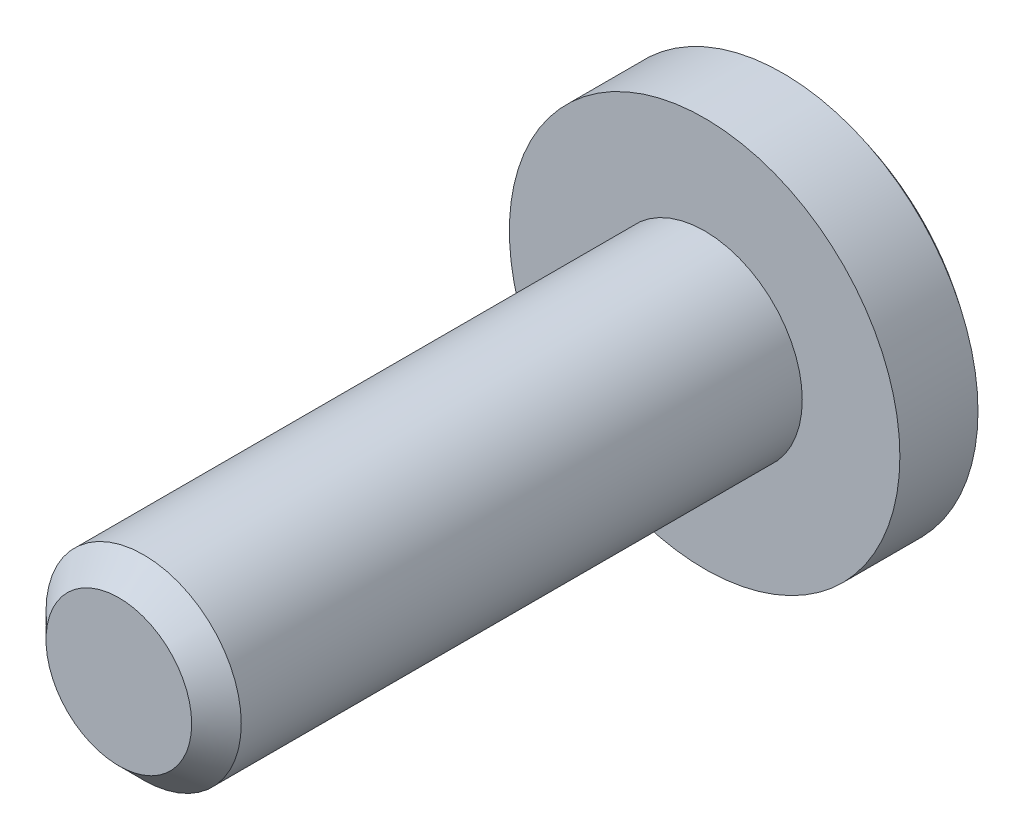
from build123d import *

# Parameters (mm, degrees)
SKETCH2_W      = 0.6
SKETCH2_H      = 1.518456807
EXTRUDE1_DEPTH = 1.27
SKETCH3_W      = 1.103174595
SKETCH3_H      = 0.588939024
EXTRUDE2_DEPTH = 1.27
CHAMFER1_SIZE  = 0.254


with BuildPart() as part:
    # Sketch1 → Revolve1 (revolve)
    with BuildSketch(Plane(origin=(0, 0, 0), x_dir=(1, 0, 0), z_dir=(0, 1, 0))):
        with BuildLine():
            Line((0, 0), (0, 7.5))
            ThreePointArc((0, 7.5), (1.059481005, 7.319945729), (2, 6.8))
            Line((2, 6.8), (2, 6))
            Line((2, 6), (1, 6))
            Line((1, 6), (1, 0))
            Line((1, 0), (0, 0))
        make_face()
    revolve(axis=Axis((0, 0, 0), (0, 0, -1)))

    # Sketch2 → Extrude1 (cut, symmetric)
    with BuildSketch(Plane(origin=(0, 0, 0), x_dir=(1, 0, 0), z_dir=(0, 1, 0))):
        with Locations((0, 7.559228404)):
            Rectangle(SKETCH2_W, SKETCH2_H)
    extrude(amount=EXTRUDE1_DEPTH, both=True, mode=Mode.SUBTRACT)

    # Sketch3 → Extrude2 (cut, symmetric)
    with BuildSketch(Plane(origin=(0, 0, 0), x_dir=(0, 0, -1), z_dir=(1, 0, 0))):
        with Locations((7.351587298, 0)):
            Rectangle(SKETCH3_W, SKETCH3_H)
    extrude(amount=EXTRUDE2_DEPTH, both=True, mode=Mode.SUBTRACT)

    # Chamfer1
    chamfer1_edges = [part.edges().sort_by_distance(p)[0] for p in [
        (-1, 0, 0),
    ]]
    chamfer(chamfer1_edges, length=CHAMFER1_SIZE)


solid = part.part
